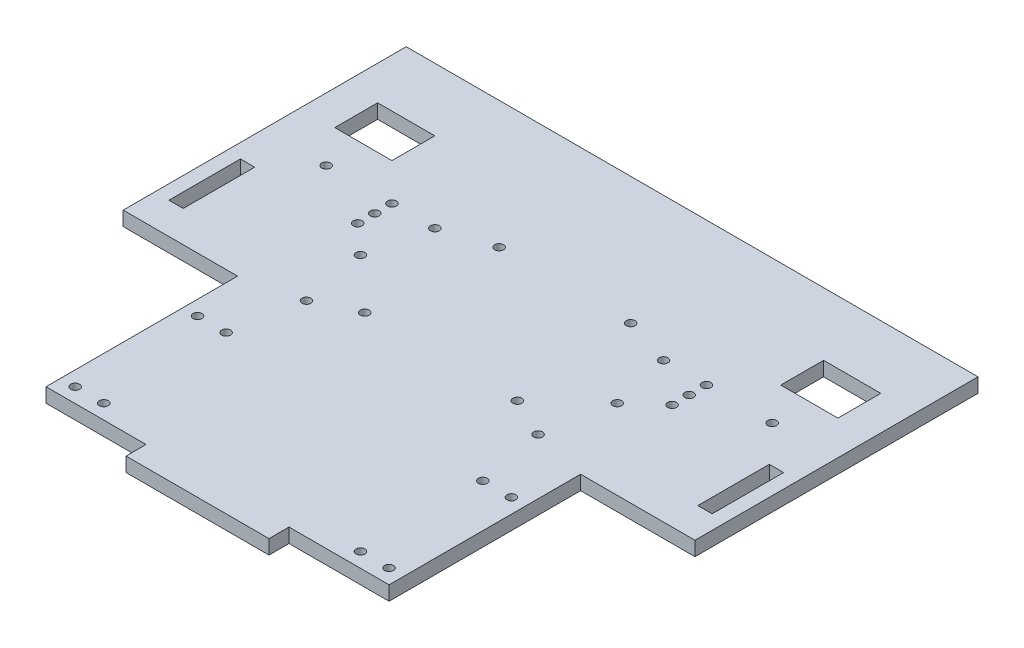
from build123d import *

# Parameters (mm, degrees)
SKETCH1_R           = 1.55
SKETCH1_W           = 20
SKETCH1_H           = 15
SKETCH1_W_2         = 5
SKETCH1_H_2         = 25
BOSS_EXTRUDE2_DEPTH = 5


with BuildPart() as part:
    # Sketch1 → Boss-Extrude2 (new body)
    with BuildSketch(Plane(origin=(0, 0, 0), x_dir=(1, 0, 0), z_dir=(0, 1, 0))):
        Polygon((-25, -75), (25, -75), (25, -68), (60, -68), (60, -1), (100, -1), (100, 0), (100, 98), (-100, 98), (-100, 0), (-100, -1), (-60, -1), (-60, -68), (-25, -68), align=None)
        with Locations((-78, 48)):
            Circle(SKETCH1_R, mode=Mode.SUBTRACT)
        with Locations((78, 48)):
            Circle(SKETCH1_R, mode=Mode.SUBTRACT)
        with Locations((-40, 48)):
            Circle(SKETCH1_R, mode=Mode.SUBTRACT)
        with Locations((40, 48)):
            Circle(SKETCH1_R, mode=Mode.SUBTRACT)
        with Locations((-44.9, 26.9)):
            Circle(SKETCH1_R, mode=Mode.SUBTRACT)
        with Locations((44.9, 26.9)):
            Circle(SKETCH1_R, mode=Mode.SUBTRACT)
        with Locations((-44.9, -62.9)):
            Circle(SKETCH1_R, mode=Mode.SUBTRACT)
        with Locations((-44.9, -20.1)):
            Circle(SKETCH1_R, mode=Mode.SUBTRACT)
        with Locations((-54.9, -62.9)):
            Circle(SKETCH1_R, mode=Mode.SUBTRACT)
        with Locations((-54.9, -20.1)):
            Circle(SKETCH1_R, mode=Mode.SUBTRACT)
        with Locations((44.9, -62.9)):
            Circle(SKETCH1_R, mode=Mode.SUBTRACT)
        with Locations((54.9, -62.9)):
            Circle(SKETCH1_R, mode=Mode.SUBTRACT)
        with Locations((44.9, -20.1)):
            Circle(SKETCH1_R, mode=Mode.SUBTRACT)
        with Locations((54.9, -20.1)):
            Circle(SKETCH1_R, mode=Mode.SUBTRACT)
        with Locations((-55, 48)):
            Circle(SKETCH1_R, mode=Mode.SUBTRACT)
        with Locations((55, 48)):
            Circle(SKETCH1_R, mode=Mode.SUBTRACT)
        with Locations((-26.7, 10.2)):
            Circle(SKETCH1_R, mode=Mode.SUBTRACT)
        with Locations((26.7, 10.2)):
            Circle(SKETCH1_R, mode=Mode.SUBTRACT)
        with Locations((-40.5, 3.605469995)):
            Circle(SKETCH1_R, mode=Mode.SUBTRACT)
        with Locations((40.5, 3.605469995)):
            Circle(SKETCH1_R, mode=Mode.SUBTRACT)
        with Locations((-23, 53.5)):
            Circle(SKETCH1_R, mode=Mode.SUBTRACT)
        with Locations((23, 53.5)):
            Circle(SKETCH1_R, mode=Mode.SUBTRACT)
        with Locations((-55, 42)):
            Circle(SKETCH1_R, mode=Mode.SUBTRACT)
        with Locations((-55, 36)):
            Circle(SKETCH1_R, mode=Mode.SUBTRACT)
        with Locations((55, 36)):
            Circle(SKETCH1_R, mode=Mode.SUBTRACT)
        with Locations((55, 42)):
            Circle(SKETCH1_R, mode=Mode.SUBTRACT)
        with Locations((-78, 68.5)):
            Rectangle(SKETCH1_W, SKETCH1_H, mode=Mode.SUBTRACT)
        with Locations((78, 68.5)):
            Rectangle(SKETCH1_W, SKETCH1_H, mode=Mode.SUBTRACT)
        with Locations((-92.5, 22.5)):
            Rectangle(SKETCH1_W_2, SKETCH1_H_2, mode=Mode.SUBTRACT)
        with Locations((92.5, 22.5)):
            Rectangle(SKETCH1_W_2, SKETCH1_H_2, mode=Mode.SUBTRACT)
    extrude(amount=BOSS_EXTRUDE2_DEPTH)


solid = part.part
